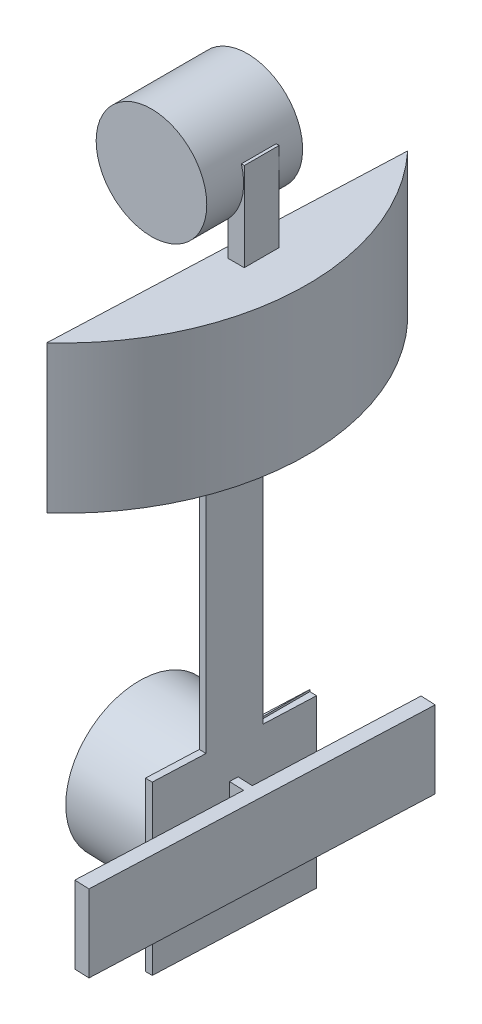
from build123d import *

# Parameters (mm, degrees)
BOSS_EXTRUDE1_DEPTH  = 20
BOSS_EXTRUDE2_DEPTH  = 60
SKETCH3_R            = 10
BOSS_EXTRUDE3_DEPTH  = 12
SKETCH6_R            = 1.5
BOSS_EXTRUDE4_DEPTH  = 3
SKETCH7_W            = 45.133553402
SKETCH7_H            = 10.461726886
BOSS_EXTRUDE5_DEPTH  = 4
SKETCH9_W            = 2
SKETCH9_H            = 10.461726886
CUT_EXTRUDE2_DEPTH   = 22
SKETCH10_W           = 2
SKETCH10_H           = 10.461726886
CUT_EXTRUDE3_DEPTH   = 22
CUT_EXTRUDE7_DEPTH   = 60
CUT_EXTRUDE8_DEPTH   = 60
SKETCH20_W           = 0.930986134
SKETCH20_H           = 37.401550855
CUT_EXTRUDE9_DEPTH   = 7
SKETCH21_W           = 7
SKETCH21_H           = 37.143096713
CUT_EXTRUDE10_DEPTH  = 7
SKETCH24_W           = 7
SKETCH24_H           = 37.288200147
CUT_EXTRUDE11_DEPTH  = 7
SKETCH25_W           = 0.930986134
SKETCH25_H           = 37.288200147
CUT_EXTRUDE12_DEPTH  = 7
SKETCH31_W           = 2.173787646
SKETCH31_H           = 4.725625318
BOSS_EXTRUDE8_DEPTH  = 12
SKETCH32_R           = 7.5
BOSS_EXTRUDE12_DEPTH = 5
SKETCH35_R           = 7.5
BOSS_EXTRUDE14_DEPTH = 8


with BuildPart() as part:
    # Sketch1 → Boss-Extrude1 (new body)
    with BuildSketch(Plane(origin=(0, 0, 0), x_dir=(1, 0, 0), z_dir=(0, 1, 0))):
        with BuildLine():
            Line((24.096630412, 22.546671656), (22.159303529, -24.453328344))
            ThreePointArc((22.159303529, -24.453328344), (32.972001095, -1.359096683), (24.096630412, 22.546671656))
        make_face()
    extrude(amount=BOSS_EXTRUDE1_DEPTH)

    # Sketch2 → Boss-Extrude2 (add)
    with BuildSketch(Plane.XZ):
        with BuildLine():
            Line((22.159303529, 24.453328344), (24.096630412, -22.546671656))
            ThreePointArc((24.096630412, -22.546671656), (24.546704066, -22.055822802), (24.986780993, -21.55599164))
            Line((24.986780993, -21.55599164), (23.127966971, 23.539268124))
            ThreePointArc((23.127966971, 23.539268124), (22.648247037, 24.001185515), (22.159303529, 24.453328344))
        make_face()
    extrude(amount=BOSS_EXTRUDE2_DEPTH)

    # Sketch3 → Boss-Extrude3 (add)
    with BuildSketch(Plane(origin=(23.127966971, 0, 0.953328344), x_dir=(-0.041184748, 0, 0.999151548), z_dir=(-0.999151548, 0, -0.041184748))):
        with Locations((0, -47)):
            Circle(SKETCH3_R)
    extrude(amount=BOSS_EXTRUDE3_DEPTH)

    # Sketch6 → Boss-Extrude4 (add)
    with BuildSketch(Plane(origin=(24.057373982, 0, 0.991638242), x_dir=(0.041184748, 0, -0.999151548), z_dir=(0.999151548, 0, 0.041184748))):
        with Locations((0, -47)):
            Circle(SKETCH6_R)
    extrude(amount=BOSS_EXTRUDE4_DEPTH)

    # Sketch7 → Boss-Extrude5 (add)
    with BuildSketch(Plane(origin=(24.057373982, 0, 0.991638242), x_dir=(0.041184748, 0, -0.999151548), z_dir=(0.999151548, 0, 0.041184748))):
        with Locations((0, -47.268051565)):
            Rectangle(SKETCH7_W, SKETCH7_H)
    extrude(amount=BOSS_EXTRUDE5_DEPTH)

    # Sketch9 → Cut-Extrude2 (cut)
    with BuildSketch(Plane(origin=(-0.929407011, 0, 22.547629882), x_dir=(0.999151548, 0, 0.041184748), z_dir=(-0.041184748, 0, 0.999151548))):
        with Locations((25.077802834, -47.268051565)):
            Rectangle(SKETCH9_W, SKETCH9_H)
    extrude(amount=-CUT_EXTRUDE2_DEPTH, mode=Mode.SUBTRACT)

    # Sketch10 → Cut-Extrude3 (cut)
    with BuildSketch(Plane(origin=(0.929407011, 0, -22.547629882), x_dir=(-0.999151548, 0, -0.041184748), z_dir=(0.041184748, 0, -0.999151548))):
        with Locations((-25.077802834, -47.268051565)):
            Rectangle(SKETCH10_W, SKETCH10_H)
    extrude(amount=-CUT_EXTRUDE3_DEPTH, mode=Mode.SUBTRACT)

    # Sketch16 → Cut-Extrude7 (cut)
    with BuildSketch(Plane.XZ.offset(60)):
        with BuildLine():
            Line((22.159303529, 24.453328344), (22.688611434, 11.612195682))
            Line((22.688611434, 11.612195682), (23.619597568, 11.612195682))
            Line((23.619597568, 11.612195682), (23.127966971, 23.539268124))
            ThreePointArc((23.127966971, 23.539268124), (22.648247037, 24.001185515), (22.159303529, 24.453328344))
        make_face()
    extrude(amount=-CUT_EXTRUDE7_DEPTH, mode=Mode.SUBTRACT)

    # Sketch19 → Cut-Extrude8 (cut)
    with BuildSketch(Plane.XZ.offset(60)):
        with BuildLine():
            Line((23.571126961, -9.797835906), (24.502113095, -9.797835906))
            Line((24.502113095, -9.797835906), (24.986780993, -21.55599164))
            ThreePointArc((24.986780993, -21.55599164), (24.546704066, -22.055822802), (24.096630412, -22.546671656))
            Line((24.096630412, -22.546671656), (23.571126961, -9.797835906))
        make_face()
    extrude(amount=-CUT_EXTRUDE8_DEPTH, mode=Mode.SUBTRACT)

    # Sketch20 → Cut-Extrude9 (cut)
    with BuildSketch(Plane(origin=(0, 0, -9.797835906), x_dir=(-1, 0, 0), z_dir=(0, 0, -1))):
        with Locations((-24.036620028, -18.700775428)):
            Rectangle(SKETCH20_W, SKETCH20_H)
    extrude(amount=-CUT_EXTRUDE9_DEPTH, mode=Mode.SUBTRACT)

    # Sketch21 → Cut-Extrude10 (cut)
    with BuildSketch(Plane(origin=(23.571126961, 0, 0), x_dir=(0, 0, -1), z_dir=(1, 0, 0))):
        with Locations((6.297835906, -18.571548357)):
            Rectangle(SKETCH21_W, SKETCH21_H)
    extrude(amount=-CUT_EXTRUDE10_DEPTH, mode=Mode.SUBTRACT)

    # Sketch24 → Cut-Extrude11 (cut)
    with BuildSketch(Plane(origin=(24.057373982, 0, 0.991638242), x_dir=(0.041184748, 0, -0.999151548), z_dir=(0.999151548, 0, 0.041184748))):
        with Locations((-7.129576122, -18.644100074)):
            Rectangle(SKETCH24_W, SKETCH24_H)
    extrude(amount=-CUT_EXTRUDE11_DEPTH, mode=Mode.SUBTRACT)

    # Sketch25 → Cut-Extrude12 (cut)
    with BuildSketch(Plane.XY.offset(11.612195682)):
        with Locations((23.154104501, -18.644100074)):
            Rectangle(SKETCH25_W, SKETCH25_H)
    extrude(amount=-CUT_EXTRUDE12_DEPTH, mode=Mode.SUBTRACT)

    # Sketch31 → Boss-Extrude8 (add)
    with BuildSketch(Plane(origin=(0, 20, 0), x_dir=(1, 0, 0), z_dir=(0, 1, 0))):
        with Locations((25.650353258, 0.109937353)):
            Rectangle(SKETCH31_W, SKETCH31_H)
    extrude(amount=BOSS_EXTRUDE8_DEPTH)

    # Sketch32 → Boss-Extrude12 (add)
    with BuildSketch(Plane.XY.offset(2.252875306)):
        with Locations((19.150620534, 29.860210164)):
            Circle(SKETCH32_R)
    extrude(amount=BOSS_EXTRUDE12_DEPTH)

    # Sketch35 → Boss-Extrude14 (add)
    with BuildSketch(Plane(origin=(0, 0, 2.252875306), x_dir=(-1, 0, 0), z_dir=(0, 0, -1))):
        with Locations((-19.150620534, 29.860210164)):
            Circle(SKETCH35_R)
    extrude(amount=BOSS_EXTRUDE14_DEPTH)


solid = part.part
